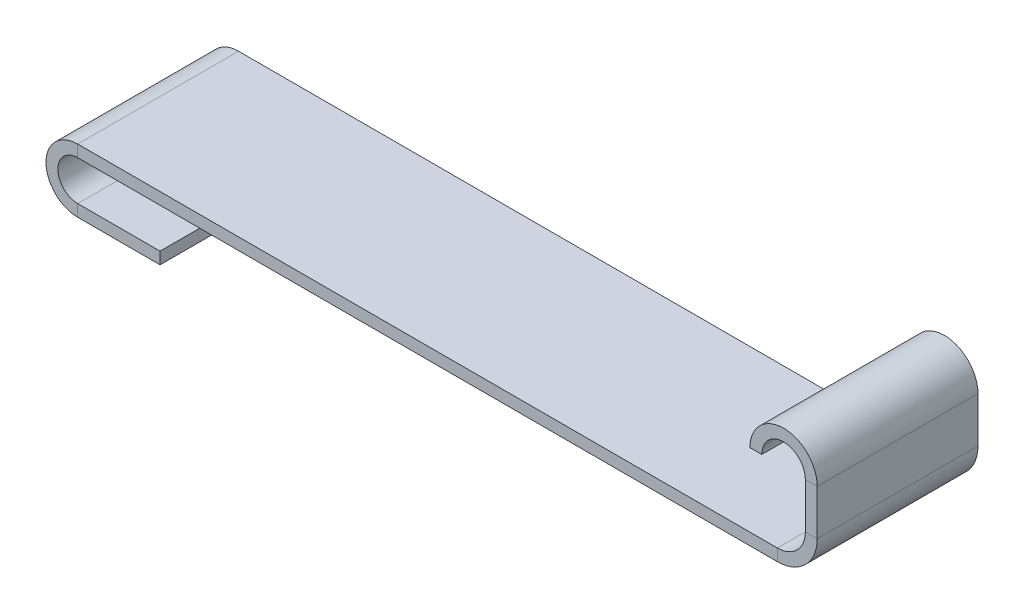
from build123d import *

# Parameters (mm, degrees)
SKETCH3_W = 2.886023393
SKETCH3_H = 39.066932482


with BuildPart() as part:
    # Sweep2: sweep along a path in Sketch1
    with BuildLine(Plane.XY) as sweep2_path:
        Line((-36.603003432, -168.172424508), (-56.603003432, -168.172424508))
        ThreePointArc((-56.603003432, -168.172424508), (-63.103003432, -161.672424508), (-56.603003432, -155.172424508))
        Line((-56.603003432, -155.172424508), (113.396996568, -155.172424508))
        ThreePointArc((113.396996568, -155.172424508), (119.053850818, -152.829278757), (121.396996568, -147.172424508))
        Line((121.396996568, -147.172424508), (121.396996568, -136.172424508))
        ThreePointArc((121.396996568, -136.172424508), (114.896996568, -129.672424508), (108.396996568, -136.172424508))
    # Sketch3 → Sweep2 (sweep)
    with BuildSketch(Plane(origin=(108.396996568, -136.172424508, 0), x_dir=(-1, 0, 0), z_dir=(0, -1, 0))):
        with Locations((0.231782983, 0)):
            Rectangle(SKETCH3_W, SKETCH3_H)
    sweep(path=sweep2_path.line)


solid = part.part
